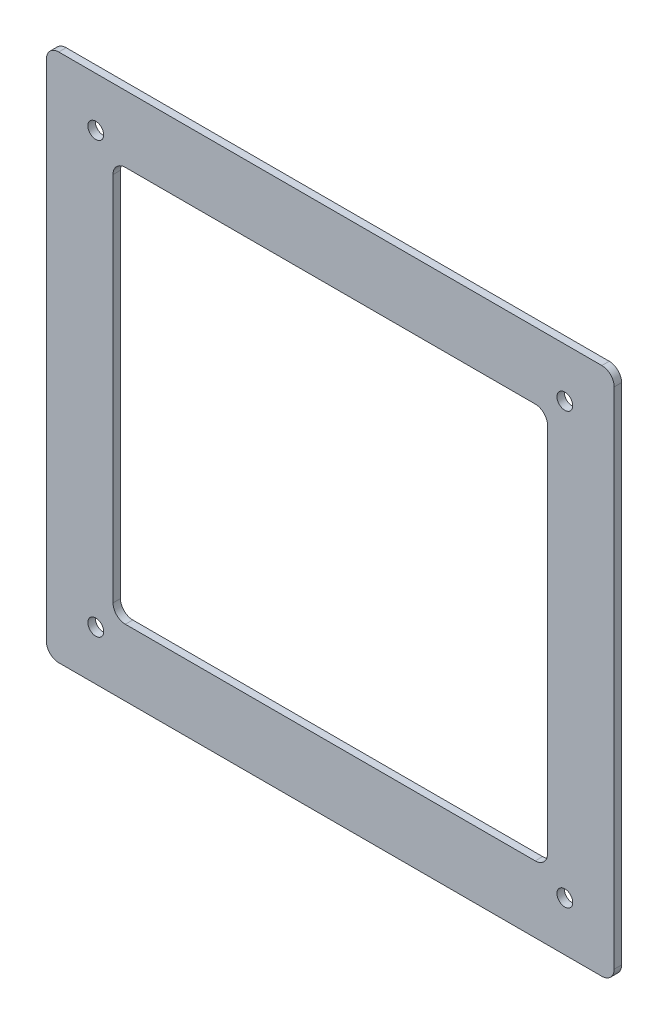
from build123d import *

# Parameters (mm, degrees)
SKETCH_1_W                  = 230
SKETCH_1_H                  = 214.25
SKETCH_1_W_2                = 176
SKETCH_1_H_2                = 160.25
EXTRUDE_1_DEPTH             = 3
FILLET_1_R                  = 5
HOLE_WIZARD_6_4_6_4_1_D     = 6.4
HOLE_WIZARD_6_4_6_4_1_DEPTH = 3


with BuildPart() as part:
    # 草图1 → 凸台-拉伸1 (new body)
    with BuildSketch(Plane.XY):
        Rectangle(SKETCH_1_W, SKETCH_1_H)
        Rectangle(SKETCH_1_W_2, SKETCH_1_H_2, mode=Mode.SUBTRACT)
    extrude(amount=EXTRUDE_1_DEPTH)

    # 圆角1
    fillet_1_edges = [part.edges().sort_by_distance(p)[0] for p in [
        (-88, 80.125, 1.5),
        (-88, -80.125, 1.5),
        (88, -80.125, 1.5),
        (88, 80.125, 1.5),
        (-115, 107.125, 1.5),
        (115, 107.125, 1.5),
        (115, -107.125, 1.5),
        (-115, -107.125, 1.5),
    ]]
    fillet(fillet_1_edges, radius=FILLET_1_R)

    # Ø6.4 (6.4) 直径孔1
    with Locations(Plane.XY.offset(3)):
        with Locations((-95, 87.125), (95, 87.125), (95, -87.125), (-95, -87.125)):
            Hole(HOLE_WIZARD_6_4_6_4_1_D / 2, depth=HOLE_WIZARD_6_4_6_4_1_DEPTH)


solid = part.part
